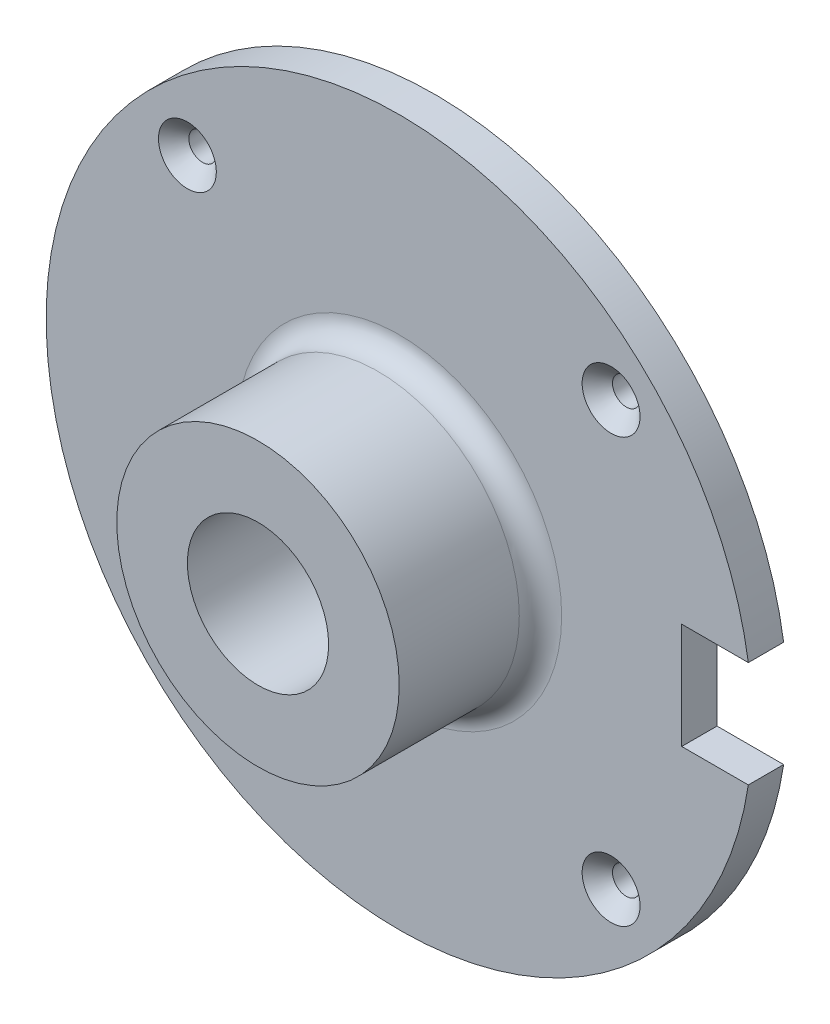
from build123d import *

# Parameters (mm, degrees)
SKETCH5_W                                         = 10
SKETCH5_H                                         = 15
EXTRUDE2_DEPTH                                    = 6
CSK_FOR_M3_5_FLAT_HEAD_MACHINE_SCREW1_D           = 3.9
CSK_FOR_M3_5_FLAT_HEAD_MACHINE_SCREW1_CSINK_D     = 8.2
CSK_FOR_M3_5_FLAT_HEAD_MACHINE_SCREW1_CSINK_ANGLE = 90
CIRPATTERN1_COUNT                                 = 4


with BuildPart() as part:
    # Sketch1 → Revolve1 (revolve)
    with BuildSketch(Plane(origin=(0, 0, 0), x_dir=(0, 0, -1), z_dir=(1, 0, 0))):
        with BuildLine():
            Line((0, 10), (-25, 10))
            Line((-25, 10), (-25, 20))
            Line((-25, 20), (-8, 20))
            ThreePointArc((-8, 20), (-5.878679656, 20.878679656), (-5, 23))
            Line((-5, 23), (-5, 50))
            Line((-5, 50), (0, 50))
            Line((0, 50), (0, 10))
        make_face()
    revolve(axis=Axis((0, 0, 50), (0, 0, -1)))

    # Sketch5 → Extrude2 (cut, through all)
    with BuildSketch(Plane.XY.offset(5)):
        with Locations((45, 0)):
            Rectangle(SKETCH5_W, SKETCH5_H)
    extrude(amount=-EXTRUDE2_DEPTH, mode=Mode.SUBTRACT)

    # CSK for M3.5 Flat Head Machine Screw1 (through all)
    with Locations(Plane.XY.offset(5)):
        with Locations((-30, 30)):
            csk_for_m3_5_flat_head_machine_screw1 = CounterSinkHole(CSK_FOR_M3_5_FLAT_HEAD_MACHINE_SCREW1_D / 2, CSK_FOR_M3_5_FLAT_HEAD_MACHINE_SCREW1_CSINK_D / 2, counter_sink_angle=CSK_FOR_M3_5_FLAT_HEAD_MACHINE_SCREW1_CSINK_ANGLE)

    # CirPattern1: CSK for M3.5 Flat Head Machine Screw1 ×4 about axis
    cirpattern1_axis = Axis((0, 0, 0), (0, 0, 1))
    for i in range(1, CIRPATTERN1_COUNT):
        add(csk_for_m3_5_flat_head_machine_screw1.rotate(cirpattern1_axis, i * 360 / CIRPATTERN1_COUNT), mode=Mode.SUBTRACT)


solid = part.part
